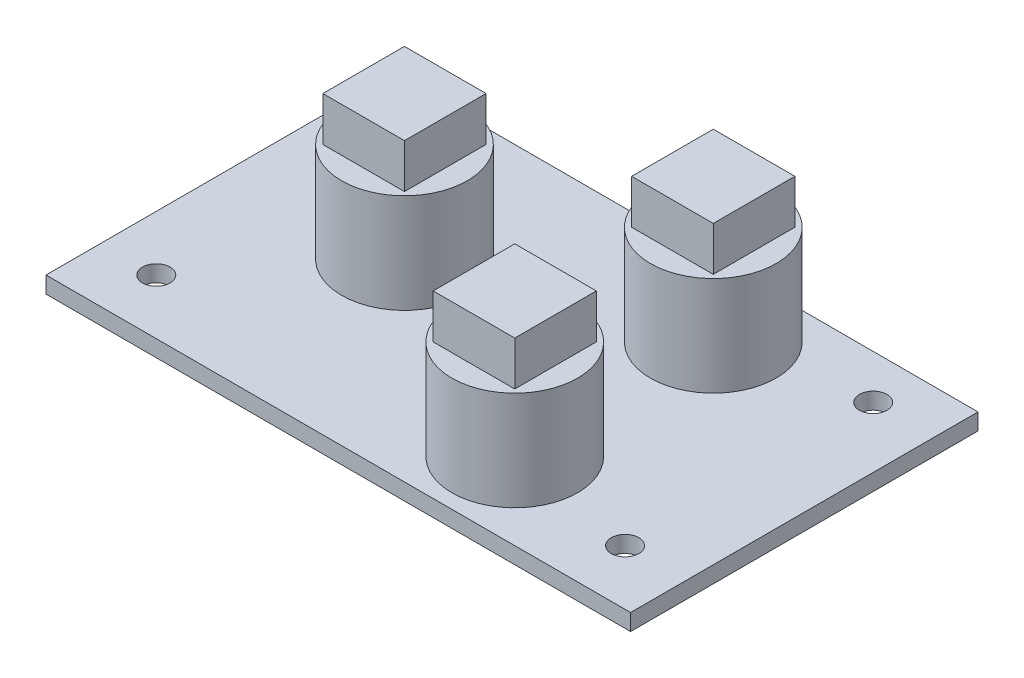
from build123d import *

# Parameters (mm, degrees)
SCHIZZO1_W                   = 53
SCHIZZO1_H                   = 31.5
ESTRUSIONE_ESTRUSIONE1_DEPTH = 1.5
SCHIZZO2_R                   = 1.25
TAGLIO_ESTRUSIONE1_DEPTH     = 1.5
SCHIZZO3_R                   = 5.7
ESTRUSIONE_ESTRUSIONE2_DEPTH = 9
SCHIZZO4_W                   = 7.4
SCHIZZO4_H                   = 7.4
ESTRUSIONE_ESTRUSIONE3_DEPTH = 4


with BuildPart() as part:
    # Schizzo1 → Estrusione-Estrusione1 (new body)
    with BuildSketch(Plane(origin=(0, 0, 0), x_dir=(1, 0, 0), z_dir=(0, 1, 0))):
        Rectangle(SCHIZZO1_W, SCHIZZO1_H)
    extrude(amount=ESTRUSIONE_ESTRUSIONE1_DEPTH)

    # Schizzo2 → Taglio-Estrusione1 (cut)
    with BuildSketch(Plane(origin=(0, 1.5, 0), x_dir=(1, 0, 0), z_dir=(0, 1, 0))):
        with Locations((-21.5, 11.75)):
            Circle(SCHIZZO2_R)
        with Locations((21, 11.75)):
            Circle(SCHIZZO2_R)
        with Locations((21, -10.75)):
            Circle(SCHIZZO2_R)
        with Locations((-21.5, -10.75)):
            Circle(SCHIZZO2_R)
    extrude(amount=-TAGLIO_ESTRUSIONE1_DEPTH, mode=Mode.SUBTRACT)

    # Schizzo3 → Estrusione-Estrusione2 (add)
    with BuildSketch(Plane(origin=(0, 1.5, 0), x_dir=(1, 0, 0), z_dir=(0, 1, 0))):
        with Locations((-11.5, 1.75)):
            Circle(SCHIZZO3_R)
        with Locations((9, -8.75)):
            Circle(SCHIZZO3_R)
        with Locations((9, 9.25)):
            Circle(SCHIZZO3_R)
    extrude(amount=ESTRUSIONE_ESTRUSIONE2_DEPTH)

    # Schizzo4 → Estrusione-Estrusione3 (add)
    with BuildSketch(Plane(origin=(0, 10.5, 0), x_dir=(1, 0, 0), z_dir=(0, 1, 0))):
        with Locations((-11.5, 1.75)):
            Rectangle(SCHIZZO4_W, SCHIZZO4_H)
        with Locations((9, 9.25)):
            Rectangle(SCHIZZO4_W, SCHIZZO4_H)
        with Locations((9, -8.75)):
            Rectangle(SCHIZZO4_W, SCHIZZO4_H)
    extrude(amount=ESTRUSIONE_ESTRUSIONE3_DEPTH)


solid = part.part
